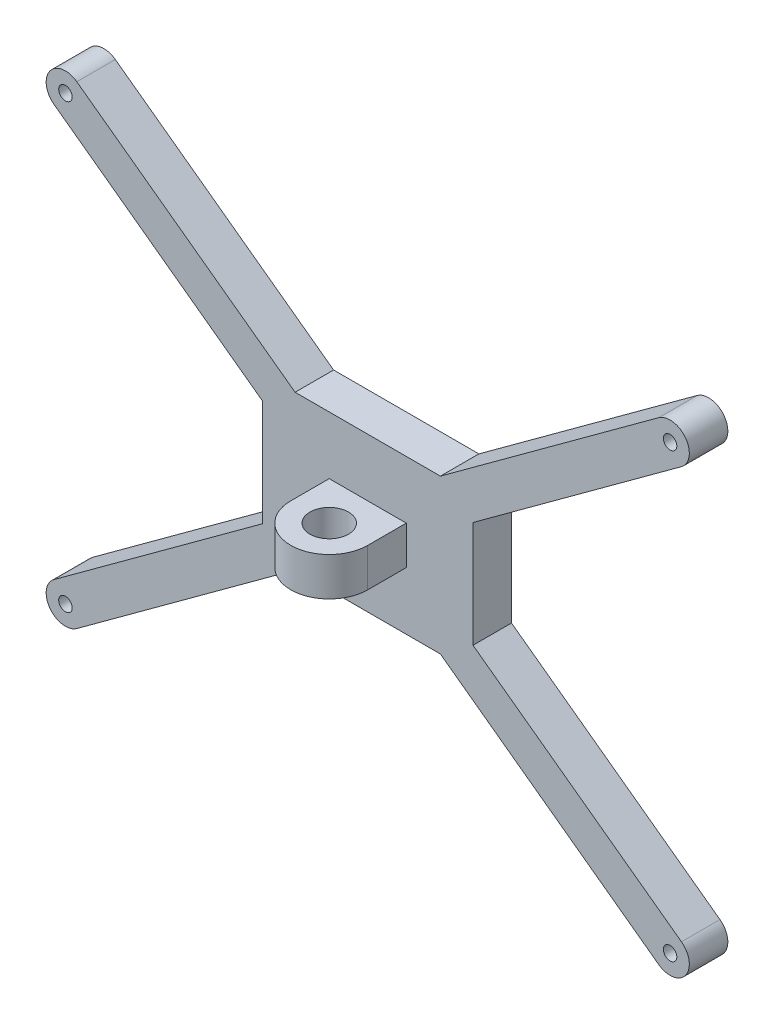
from build123d import *

# Parameters (mm, degrees)
ESQUISSE1_R        = 1.75
BOSS_EXTRU_1_DEPTH = 10
BOSS_EXTRU_3_START = 15
ESQUISSE4_R        = 5
BOSS_EXTRU_3_DEPTH = 10


with BuildPart() as part:
    # Esquisse1 → Boss.-Extru.1 (new body)
    with BuildSketch(Plane.XY):
        with BuildLine():
            Line((-2.952917385, 110.865117237), (51.171888599, 71.254033112))
            Line((51.171888599, 71.254033112), (51.171888599, 43.645966888))
            Line((51.171888599, 43.645966888), (-2.952917385, 4.034882763))
            ThreePointArc((-2.952917385, 4.034882763), (-4.034882763, -2.952917385), (2.952917385, -4.034882763))
            Line((2.952917385, -4.034882763), (59.638092267, 37.45))
            Line((59.638092267, 37.45), (97.361907733, 37.45))
            Line((97.361907733, 37.45), (154.047082615, -4.034882763))
            ThreePointArc((154.047082615, -4.034882763), (161.034882763, -2.952917385), (159.952917385, 4.034882763))
            Line((159.952917385, 4.034882763), (105.828111401, 43.645966888))
            Line((105.828111401, 43.645966888), (105.828111401, 71.254033112))
            Line((105.828111401, 71.254033112), (159.952917385, 110.865117237))
            ThreePointArc((159.952917385, 110.865117237), (161.034882763, 117.852917385), (154.047082615, 118.934882763))
            Line((154.047082615, 118.934882763), (97.361907733, 77.45))
            Line((97.361907733, 77.45), (59.638092267, 77.45))
            Line((59.638092267, 77.45), (2.952917385, 118.934882763))
            ThreePointArc((2.952917385, 118.934882763), (-4.034882763, 117.852917385), (-2.952917385, 110.865117237))
        make_face()
        Circle(ESQUISSE1_R, mode=Mode.SUBTRACT)
        with Locations((0, 114.9)):
            Circle(ESQUISSE1_R, mode=Mode.SUBTRACT)
        with Locations((157, 0)):
            Circle(ESQUISSE1_R, mode=Mode.SUBTRACT)
        with Locations((157, 114.9)):
            Circle(ESQUISSE1_R, mode=Mode.SUBTRACT)
    extrude(amount=BOSS_EXTRU_1_DEPTH)

    # Esquisse4 → Boss.-Extru.3 (add)
    with BuildSketch(Plane(origin=(0, 37.45, 123.316242038), x_dir=(1, 0, 0), z_dir=(0, 1, 0)).offset(BOSS_EXTRU_3_START)):
        with BuildLine():
            Line((88.5, 113.316242038), (88.5, 103.316242038))
            ThreePointArc((88.5, 103.316242038), (78.5, 93.316242038), (68.5, 103.316242038))
            Line((68.5, 103.316242038), (68.5, 113.316242038))
            Line((68.5, 113.316242038), (88.5, 113.316242038))
        make_face()
        with Locations((78.5, 103.316242038)):
            Circle(ESQUISSE4_R, mode=Mode.SUBTRACT)
    extrude(amount=BOSS_EXTRU_3_DEPTH)


solid = part.part
